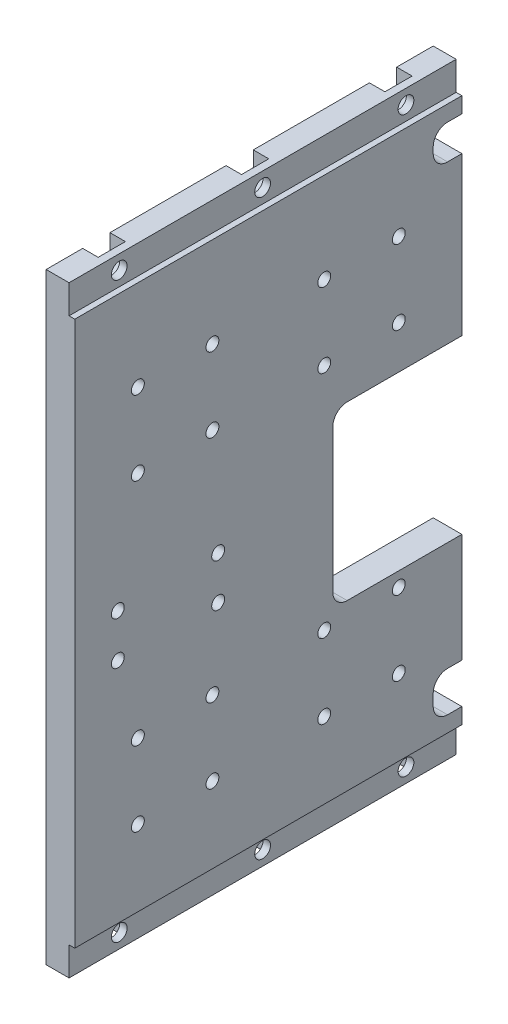
from build123d import *

# Parameters (mm, degrees)
SKETCH1_W                  = 135
SKETCH1_H                  = 210
BOSS_EXTRUDE1_DEPTH        = 10
SKETCH2_W                  = 45
SKETCH2_H                  = 60
CUT_EXTRUDE1_DEPTH         = 11
SKETCH3_W                  = 10
SKETCH3_H                  = 14
SKETCH3_H_2                = 12
CUT_EXTRUDE2_DEPTH         = 11
SKETCH4_W                  = 135
SKETCH4_H                  = 10
CUT_EXTRUDE3_DEPTH         = 2
SKETCH5_R                  = 2.5
CUT_EXTRUDE4_DEPTH         = 6
CUT_EXTRUDE5_DEPTH         = 5.4
LPATTERN1_COUNT            = 3
LPATTERN1_PITCH            = 50
F_5_5_5_5_DIAMETER_HOLE1_D = 5.5
LPATTERN3_COUNT            = 3
LPATTERN3_PITCH            = 50
F_4_5_4_5_DIAMETER_HOLE1_D = 4.5
F_4_5_4_5_DIAMETER_HOLE2_D = 4.5
LPATTERN2_COUNT            = 2
LPATTERN2_PITCH            = 65
LPATTERN2_COUNT_DIR2       = 2
LPATTERN2_PITCH_DIR2       = 106
FILLET1_R                  = 5


with BuildPart() as part:
    # Sketch1 → Boss-Extrude1 (new body)
    with BuildSketch(Plane(origin=(0, 0, 0), x_dir=(0, 0, -1), z_dir=(1, 0, 0))):
        with Locations((67.5, 105)):
            Rectangle(SKETCH1_W, SKETCH1_H)
    extrude(amount=BOSS_EXTRUDE1_DEPTH)

    # Sketch2 → Cut-Extrude1 (cut, through all)
    with BuildSketch(Plane(origin=(10, 0, 0), x_dir=(0, 0, -1), z_dir=(1, 0, 0))):
        with Locations((112.5, 97.5)):
            Rectangle(SKETCH2_W, SKETCH2_H)
    extrude(amount=-CUT_EXTRUDE1_DEPTH, mode=Mode.SUBTRACT)

    # Sketch3 → Cut-Extrude2 (cut, through all)
    with BuildSketch(Plane(origin=(10, 0, 0), x_dir=(0, 0, -1), z_dir=(1, 0, 0))):
        with Locations((130, 22.5)):
            Rectangle(SKETCH3_W, SKETCH3_H)
        with Locations((130, 188.5)):
            Rectangle(SKETCH3_W, SKETCH3_H_2)
    extrude(amount=-CUT_EXTRUDE2_DEPTH, mode=Mode.SUBTRACT)

    # Sketch4 → Cut-Extrude3 (cut)
    with BuildSketch(Plane(origin=(10, 0, 0), x_dir=(0, 0, -1), z_dir=(1, 0, 0))):
        with Locations((67.5, 5)):
            Rectangle(SKETCH4_W, SKETCH4_H)
        with Locations((67.5, 205)):
            Rectangle(SKETCH4_W, SKETCH4_H)
    extrude(amount=-CUT_EXTRUDE3_DEPTH, mode=Mode.SUBTRACT)

    # Sketch5 → Cut-Extrude4 (cut)
    with BuildSketch(Plane.ZY):
        with Locations((-35, 175)):
            Circle(SKETCH5_R)
        with Locations((-100, 175)):
            Circle(SKETCH5_R)
    extrude(amount=-CUT_EXTRUDE4_DEPTH, mode=Mode.SUBTRACT)

    # Sketch6 → Cut-Extrude5 (cut)
    with BuildSketch(Plane.ZY):
        with BuildLine():
            Line((-22.25, 5), (-22.25, 0))
            Line((-22.25, 0), (-12.75, 0))
            Line((-12.75, 0), (-12.75, 5))
            ThreePointArc((-12.75, 5), (-17.5, 9.75), (-22.25, 5))
        make_face()
        with BuildLine():
            Line((-22.25, 205), (-22.25, 210))
            Line((-22.25, 210), (-12.75, 210))
            Line((-12.75, 210), (-12.75, 205))
            ThreePointArc((-12.75, 205), (-17.5, 200.25), (-22.25, 205))
        make_face()
    cut_extrude5 = extrude(amount=-CUT_EXTRUDE5_DEPTH, mode=Mode.SUBTRACT)

    # LPattern1: Cut-Extrude5 ×3
    with Locations(*[(0, 0, -i * LPATTERN1_PITCH) for i in range(1, LPATTERN1_COUNT)]):
        add(cut_extrude5, mode=Mode.SUBTRACT)

    # Ø5.5 (5.5) Diameter Hole1 (through all)
    with Locations(Plane.ZY.offset(-5.4)):
        with Locations((-17.5, 205), (-17.5, 5)):
            f_5_5_5_5_diameter_hole1 = Hole(F_5_5_5_5_DIAMETER_HOLE1_D / 2)

    # LPattern3: Ø5.5 (5.5) Diameter Hole1 ×3
    with Locations(*[(0, 0, -i * LPATTERN3_PITCH) for i in range(1, LPATTERN3_COUNT)]):
        add(f_5_5_5_5_diameter_hole1, mode=Mode.SUBTRACT)

    # Ø4.5 (4.5) Diameter Hole1 (through all)
    with Locations(Plane(origin=(10, 0, 0), x_dir=(0, 0, -1), z_dir=(1, 0, 0))):
        with Locations((15, 104.4), (50, 104.4), (15, 89.4), (50, 89.4)):
            Hole(F_4_5_4_5_DIAMETER_HOLE1_D / 2)

    # Ø4.5 (4.5) Diameter Hole2 (through all)
    with Locations(Plane(origin=(10, 0, 0), x_dir=(0, 0, -1), z_dir=(1, 0, 0))):
        with Locations((22, 36.5), (22, 62.5), (48, 62.5), (48, 36.5)):
            f_4_5_4_5_diameter_hole2 = Hole(F_4_5_4_5_DIAMETER_HOLE2_D / 2)

    # LPattern2: 4.5 _4.5_ Diameter Hole2 2 × 2
    with Locations(*[(0, j * LPATTERN2_PITCH_DIR2, -i * LPATTERN2_PITCH) for i in range(LPATTERN2_COUNT) for j in range(LPATTERN2_COUNT_DIR2) if (i, j) != (0, 0)]):
        add(f_4_5_4_5_diameter_hole2, mode=Mode.SUBTRACT)

    # Fillet1
    fillet1_edges = [part.edges().sort_by_distance(p)[0] for p in [
        (5, 67.5, -90),
        (5, 127.5, -90),
        (5, 15.5, -125),
        (5, 29.5, -125),
        (5, 182.5, -125),
        (5, 194.5, -125),
    ]]
    fillet(fillet1_edges, radius=FILLET1_R)


solid = part.part
